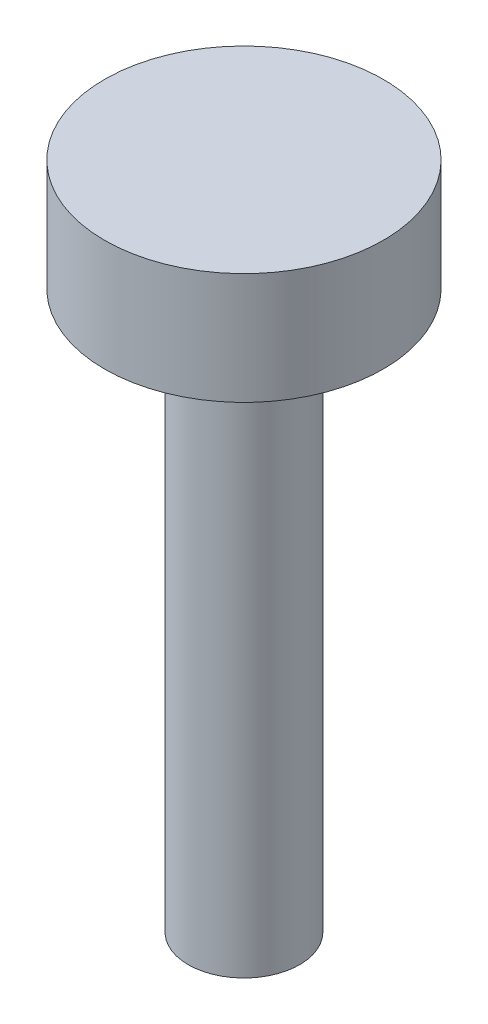
from build123d import *

# Parameters (mm, degrees)
SKETCH4_R           = 10
BOSS_EXTRUDE5_DEPTH = 100
SKETCH5_R           = 25
BOSS_EXTRUDE6_DEPTH = 20


with BuildPart() as part:
    # Sketch4 → Boss-Extrude5 (new body)
    with BuildSketch(Plane(origin=(0, 0, 0), x_dir=(1, 0, 0), z_dir=(0, 1, 0))):
        Circle(SKETCH4_R)
    extrude(amount=BOSS_EXTRUDE5_DEPTH)

    # Sketch5 → Boss-Extrude6 (add)
    with BuildSketch(Plane(origin=(0, 100, 0), x_dir=(1, 0, 0), z_dir=(0, 1, 0))):
        Circle(SKETCH5_R)
    extrude(amount=BOSS_EXTRUDE6_DEPTH)


solid = part.part
